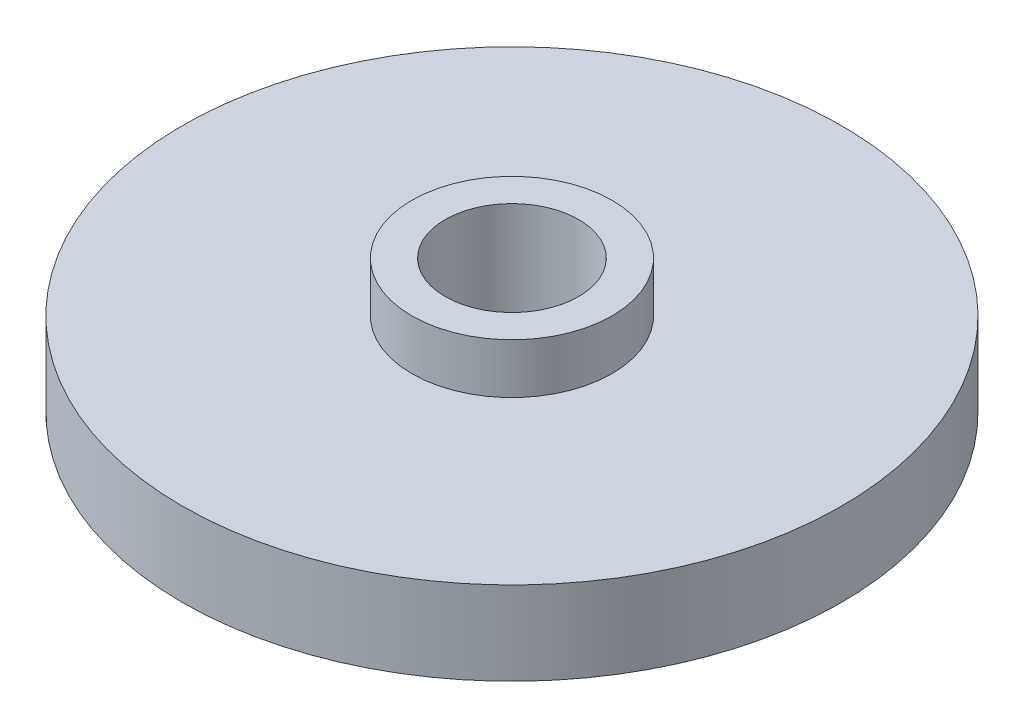
from build123d import *

# Parameters (mm, degrees)
SKETCH_1_R          = 19.75
EXTRUDE_1_DEPTH     = 5
SKETCH_2_R          = 6
EXTRUDE_2_DEPTH     = 3
SKETCH_3_R          = 4.7
EXTRUDE_3_DEPTH     = 0.65
SKETCH_4_R          = 1.6
CUT_EXTRUDE_1_DEPTH = 9.65
SKETCH_5_R          = 3.85
CUT_EXTRUDE_2_DEPTH = 0.85
SKETCH_6_R          = 4
CUT_EXTRUDE_3_DEPTH = 5.8


with BuildPart() as part:
    # 草圖1 → 填料-伸長1 (new body)
    with BuildSketch(Plane(origin=(0, 0, 0), x_dir=(1, 0, 0), z_dir=(0, 1, 0))):
        Circle(SKETCH_1_R)
    extrude(amount=EXTRUDE_1_DEPTH)

    # 草圖2 → 填料-伸長2 (add)
    with BuildSketch(Plane(origin=(0, 5, 0), x_dir=(1, 0, 0), z_dir=(0, 1, 0))):
        Circle(SKETCH_2_R)
    extrude(amount=EXTRUDE_2_DEPTH)

    # 草圖3 → 填料-伸長3 (add)
    with BuildSketch(Plane.XZ):
        Circle(SKETCH_3_R)
    extrude(amount=EXTRUDE_3_DEPTH)

    # 草圖4 → 除料-伸長1 (cut, through all)
    with BuildSketch(Plane.XZ.offset(0.65)):
        Circle(SKETCH_4_R)
    extrude(amount=-CUT_EXTRUDE_1_DEPTH, mode=Mode.SUBTRACT)

    # 草圖5 → 除料-伸長2 (cut)
    with BuildSketch(Plane.XZ.offset(0.65)):
        Circle(SKETCH_5_R)
    extrude(amount=-CUT_EXTRUDE_2_DEPTH, mode=Mode.SUBTRACT)

    # 草圖6 → 除料-伸長3 (cut)
    with BuildSketch(Plane(origin=(0, 8, 0), x_dir=(1, 0, 0), z_dir=(0, 1, 0))):
        Circle(SKETCH_6_R)
    extrude(amount=-CUT_EXTRUDE_3_DEPTH, mode=Mode.SUBTRACT)


solid = part.part
